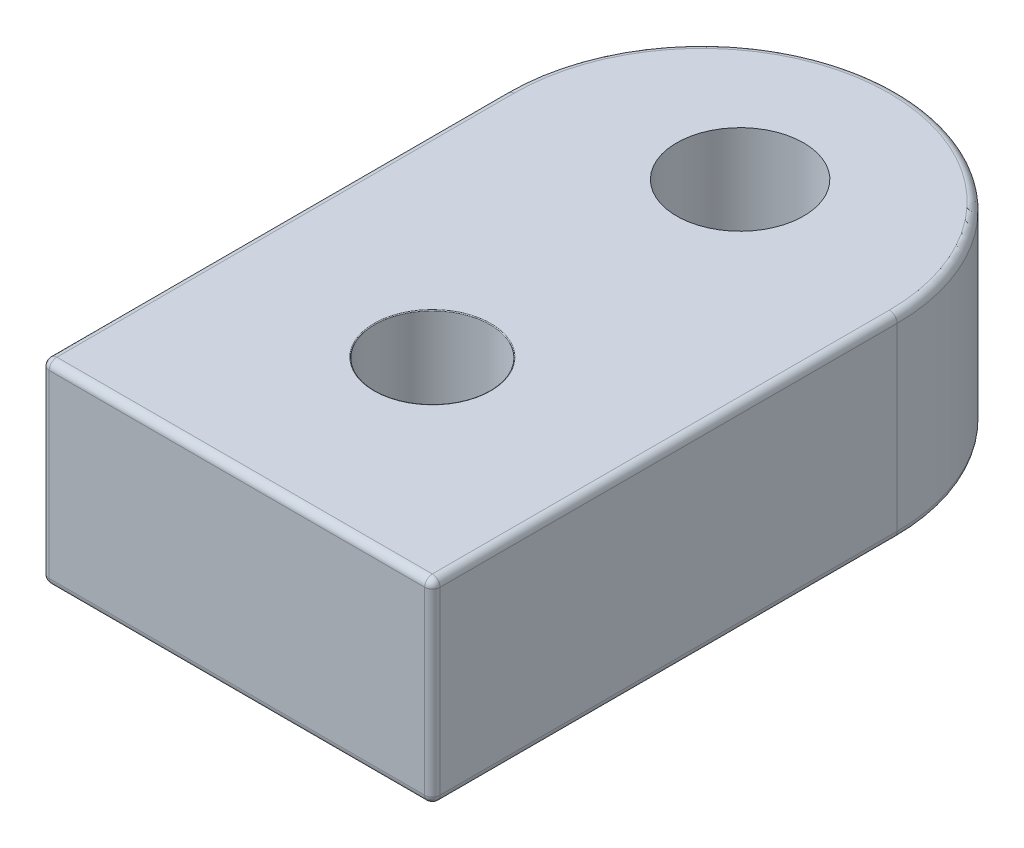
from build123d import *

# Parameters (mm, degrees)
SKETCH1_W               = 25.4
SKETCH1_H               = 35
BOSS_EXTRUDE1_DEPTH     = 12.7
FILLET1_R               = 0.05
SKETCH4_R               = 0.775
BOSS_EXTRUDE2_DEPTH     = 2
FILLET2_R               = 0.1
BOSS_EXTRUDE3_DEPTH     = 12.7
FILLET3_R               = 0.5
SKETCH12_W              = 28.953239704
SKETCH12_H              = 4.8
CUT_EXTRUDE6_DEPTH      = 13.7
CUT_EXTRUDE6_DEPTH_BACK = 3
SKETCH10_R              = 4.125
CUT_EXTRUDE1_DEPTH      = 3
CUT_EXTRUDE1_DEPTH_BACK = 13.7
SKETCH11_R              = 0.9
CUT_EXTRUDE3_DEPTH      = 3
CUT_EXTRUDE3_DEPTH_BACK = 5
FILLET4_R               = 0.5


with BuildPart() as part:
    # Sketch1 → Boss-Extrude1 (new body)
    with BuildSketch(Plane(origin=(0, 0, 0), x_dir=(1, 0, 0), z_dir=(0, 1, 0))):
        Rectangle(SKETCH1_W, SKETCH1_H)
    extrude(amount=BOSS_EXTRUDE1_DEPTH)

    # Sketch2 → Cut-Revolve1 (revolve, cut)
    with BuildSketch(Plane.XY):
        Polygon((3.75, 12.7), (3.75, 4.5), (2.05, 4.5), (2.05, 0), (0, 0), (0, 12.7), align=None)
    revolve(axis=Axis((0, 7.839551451, 0), (0, -1, 0)), mode=Mode.SUBTRACT)

    # Fillet1
    fillet1_edges = [part.edges().sort_by_distance(p)[0] for p in [
        (-3.75, 12.7, 0),
        (-3.75, 4.5, 0),
        (-2.05, 4.5, 0),
    ]]
    fillet(fillet1_edges, radius=FILLET1_R)

    # Sketch4 → Boss-Extrude2 (add)
    with BuildSketch(Plane.XZ):
        with Locations((0, 10.16)):
            Circle(SKETCH4_R)
        with Locations((0, -10.16)):
            Circle(SKETCH4_R)
    extrude(amount=BOSS_EXTRUDE2_DEPTH)

    # Fillet2
    fillet2_edges = [part.edges().sort_by_distance(p)[0] for p in [
        (-0.775, -2, 10.16),
        (-0.775, -2, -10.16),
    ]]
    fillet(fillet2_edges, radius=FILLET2_R)

    # Sketch9 → Boss-Extrude3 (add)
    with BuildSketch(Plane(origin=(0, 12.7, 0), x_dir=(1, 0, 0), z_dir=(0, 1, 0))):
        with BuildLine():
            Line((12.7, 17.5), (-12.7, 17.5))
            ThreePointArc((-12.7, 17.5), (0, 30.2), (12.7, 17.5))
        make_face()
    extrude(amount=-BOSS_EXTRUDE3_DEPTH)

    # Fillet3
    fillet3_edges = [part.edges().sort_by_distance(p)[0] for p in [
        (12.7, 12.7, 0),
        (-12.7, 12.7, 0),
        (0, 12.7, -30.2),
        (0, 0, -30.2),
        (12.7, 0, 0),
        (0, 0, 17.5),
        (-12.7, 0, 0),
    ]]
    fillet(fillet3_edges, radius=FILLET3_R)

    # Sketch12 → Cut-Extrude6 (cut, two sides)
    with BuildSketch(Plane(origin=(0, 0, 0), x_dir=(1, 0, 0), z_dir=(0, 1, 0))) as cut_extrude6_sk:
        with Locations((1.024131642, -15.1)):
            Rectangle(SKETCH12_W, SKETCH12_H)
    extrude(amount=CUT_EXTRUDE6_DEPTH, mode=Mode.SUBTRACT)
    extrude(cut_extrude6_sk.sketch, amount=-CUT_EXTRUDE6_DEPTH_BACK, mode=Mode.SUBTRACT)

    # Sketch10 → Cut-Extrude1 (cut, two sides)
    with BuildSketch(Plane.XZ) as cut_extrude1_sk:
        with Locations((0, -20)):
            Circle(SKETCH10_R)
    extrude(amount=CUT_EXTRUDE1_DEPTH, mode=Mode.SUBTRACT)
    extrude(cut_extrude1_sk.sketch, amount=-CUT_EXTRUDE1_DEPTH_BACK, mode=Mode.SUBTRACT)

    # Sketch11 → Cut-Extrude3 (cut, two sides)
    with BuildSketch(Plane.XZ) as cut_extrude3_sk:
        with Locations((0, -10.16)):
            Circle(SKETCH11_R)
        with Locations((0, 10.16)):
            Circle(SKETCH11_R)
    extrude(amount=CUT_EXTRUDE3_DEPTH, mode=Mode.SUBTRACT)
    extrude(cut_extrude3_sk.sketch, amount=-CUT_EXTRUDE3_DEPTH_BACK, mode=Mode.SUBTRACT)

    # Fillet4
    fillet4_edges = [part.edges().sort_by_distance(p)[0] for p in [
        (12.553553391, 0.146446609, 12.7),
        (-12.553553391, 12.553553391, 12.7),
        (-12.553553391, 0.146446609, 12.7),
        (12.553553391, 12.553553391, 12.7),
        (12.7, 6.35, 12.7),
        (0, 0, 12.7),
        (-12.7, 6.35, 12.7),
        (0, 12.7, 12.7),
    ]]
    fillet(fillet4_edges, radius=FILLET4_R)


solid = part.part
